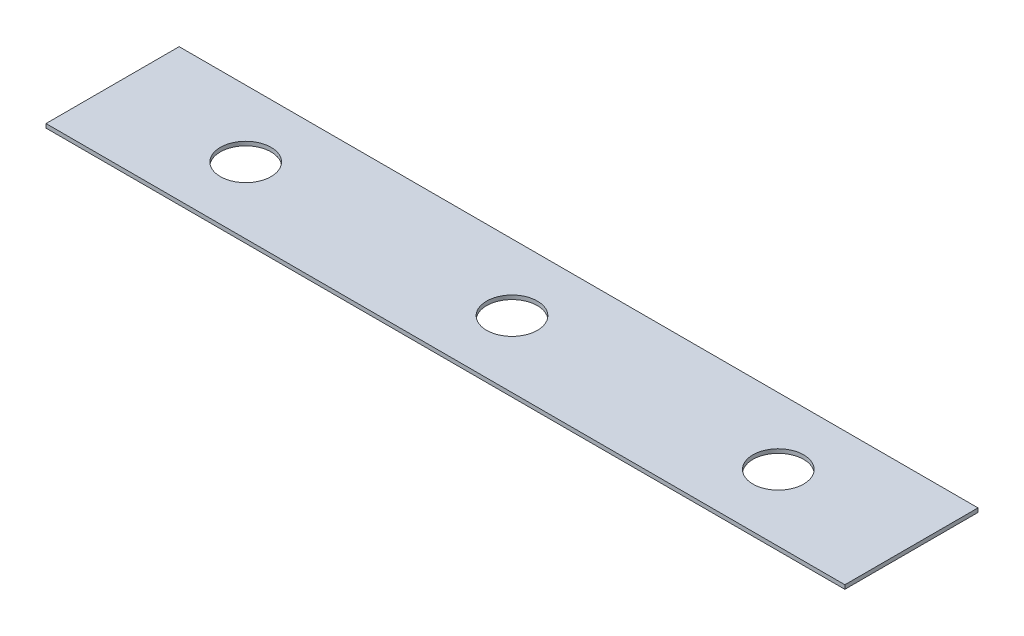
from build123d import *

# Parameters (mm, degrees)
SKETCH1_W           = 76.2
SKETCH1_H           = 12.7
BOSS_EXTRUDE1_DEPTH = 0.381
SKETCH2_R           = 2.41935
CUT_EXTRUDE1_DEPTH  = 1.381


with BuildPart() as part:
    # Sketch1 → Boss-Extrude1 (new body)
    with BuildSketch(Plane(origin=(0, 0, 0), x_dir=(1, 0, 0), z_dir=(0, 1, 0))):
        Rectangle(SKETCH1_W, SKETCH1_H)
    extrude(amount=BOSS_EXTRUDE1_DEPTH)

    # Sketch2 → Cut-Extrude1 (cut, through all)
    with BuildSketch(Plane(origin=(0, 0.381, 0), x_dir=(1, 0, 0), z_dir=(0, 1, 0))):
        Circle(SKETCH2_R)
        with Locations((-25.4, 0)):
            Circle(SKETCH2_R)
        with Locations((25.4, 0)):
            Circle(SKETCH2_R)
    extrude(amount=-CUT_EXTRUDE1_DEPTH, mode=Mode.SUBTRACT)


solid = part.part
